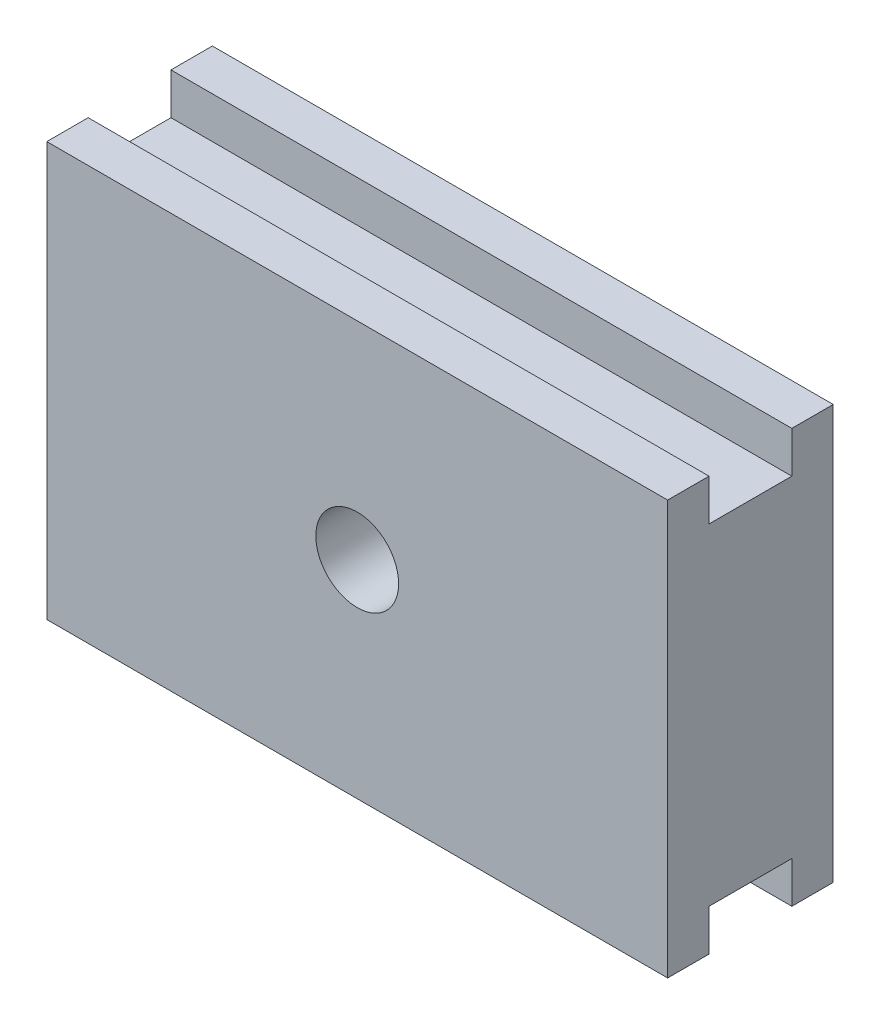
from build123d import *

# Parameters (mm, degrees)
SKETCH_1_W          = 15
SKETCH_1_H          = 10
EXTRUDE_1_DEPTH     = 4
SKETCH_2_W          = 2
SKETCH_2_H          = 1
CUT_EXTRUDE_1_DEPTH = 17.30950643
SKETCH_3_R          = 1
CUT_EXTRUDE_2_DEPTH = 10.861541462


with BuildPart() as part:
    # 草图1 → 凸台-拉伸1 (new body)
    with BuildSketch(Plane.XY):
        Rectangle(SKETCH_1_W, SKETCH_1_H)
    extrude(amount=EXTRUDE_1_DEPTH)

    # 草图2 → 切除-拉伸1 (cut, through all)
    with BuildSketch(Plane(origin=(7.5, 0, 0), x_dir=(0, 0, -1), z_dir=(1, 0, 0))):
        with Locations((-2, 4.5)):
            Rectangle(SKETCH_2_W, SKETCH_2_H)
        with Locations((-2, -4.5)):
            Rectangle(SKETCH_2_W, SKETCH_2_H)
    extrude(amount=-CUT_EXTRUDE_1_DEPTH, mode=Mode.SUBTRACT)

    # 草图3 → 切除-拉伸2 (cut, through all)
    with BuildSketch(Plane.XY.offset(4)):
        Circle(SKETCH_3_R)
    extrude(amount=-CUT_EXTRUDE_2_DEPTH, mode=Mode.SUBTRACT)


solid = part.part
